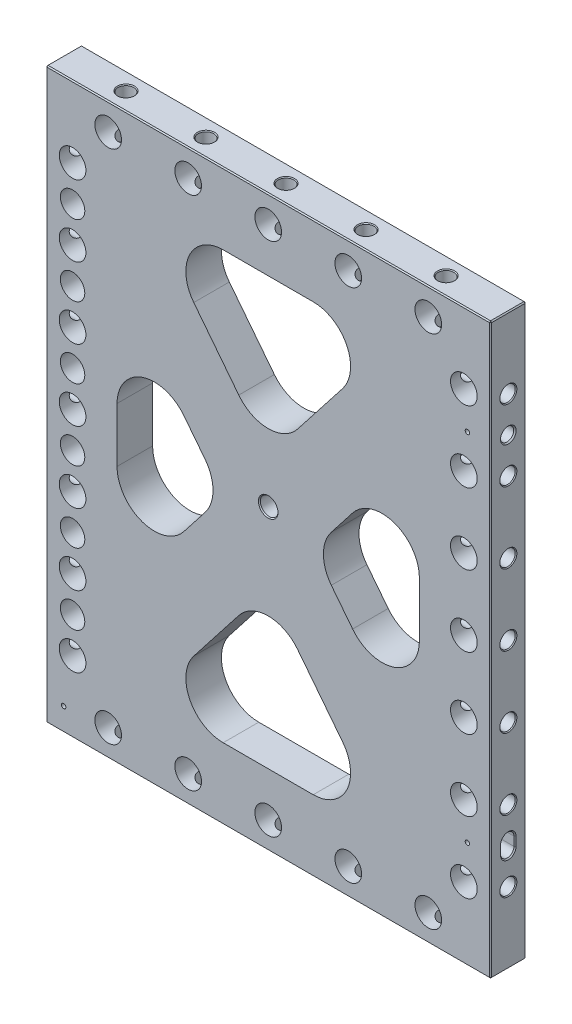
from build123d import *

# Parameters (mm, degrees)
SKETCH2_W                                     = 317.5
SKETCH2_H                                     = 406.4
EXTRUDE1_DEPTH                                = 12.7
TRIANGLES_CUT_EXTRUDE2_DEPTH                  = 26.4
TRIANGLES_FILLET1_R                           = 26.67
F_3_4_0_75_DIAMETER_HOLE2_D                   = 19.05
LPATTERN3_COUNT                               = 4
LPATTERN3_PITCH                               = 50.8
LPATTERN3_COL_COUNT                           = 4
LPATTERN3_COL_PITCH                           = 50.8
MIRROR1_COPY_1_D                              = 19.05
MIRROR1_COPY_2_D                              = 19.05
MIRROR1_COPY_3_D                              = 19.05
MIRROR1_COPY_7_D                              = 19.05
MIRROR1_COPY_8_D                              = 19.05
MIRROR1_COPY_9_D                              = 19.05
F_3_4_0_75_DIAMETER_HOLE1_D                   = 19.05
LPATTERN4_COUNT                               = 3
LPATTERN4_PITCH                               = 57.15
LPATTERN4_COL_COUNT                           = 3
LPATTERN4_COL_PITCH                           = 57.15
MIRROR2_COPY_1_D                              = 19.05
MIRROR2_COPY_2_D                              = 19.05
MIRROR2_COPY_5_D                              = 19.05
MIRROR2_COPY_6_D                              = 19.05
CBORE_FOR_3_8_SOCKET_HEAD_CAP_SCREW1_AT_COUNT = 2
CBORE_FOR_3_8_SOCKET_HEAD_CAP_SCREW1_AT_PITCH = 50.8
CBORE_FOR_3_8_SOCKET_HEAD_CAP_SCREW1_2_COUNT  = 2
CBORE_FOR_3_8_SOCKET_HEAD_CAP_SCREW1_2_PITCH  = 101.6
CBORE_FOR_3_8_SOCKET_HEAD_CAP_SCREW1_3_COUNT  = 2
CBORE_FOR_3_8_SOCKET_HEAD_CAP_SCREW1_3_PITCH  = 152.4
CBORE_FOR_3_8_SOCKET_HEAD_CAP_SCREW1_4_COUNT  = 2
CBORE_FOR_3_8_SOCKET_HEAD_CAP_SCREW1_4_PITCH  = 203.2
CBORE_FOR_3_8_SOCKET_HEAD_CAP_SCREW1_5_COUNT  = 2
CBORE_FOR_3_8_SOCKET_HEAD_CAP_SCREW1_5_PITCH  = 254
F_3_8_0_376_PIN_LOCATE1_D                     = 9.5504
F_3_8_0_376_PIN_LOCATE1_DEPTH                 = 19.05
F_3_8_0_376_PIN_LOCATE1_CSINK_D               = 11.176
F_3_8_0_376_PIN_LOCATE1_CSINK_ANGLE           = 82
F_3_8_0_376_PIN_LOCATE1_TIP                   = 2.869229628
SLOT_LOCATE1_DEPTH                            = 19.05
CHAMFER1_SIZE                                 = 0.762
F_1_8_0_125_DIAMETER_HOLE1_D                  = 3.175
F_1_8_0_125_DIAMETER_HOLE1_DEPTH              = 9.525
F_1_8_0_125_DIAMETER_HOLE1_TIP                = 0.953866233
CHAMFER2_SIZE                                 = 0.762


with BuildPart() as part:
    # Sketch2 → Extrude1 (new body, symmetric)
    with BuildSketch(Plane.XY):
        Rectangle(SKETCH2_W, SKETCH2_H)
    extrude(amount=EXTRUDE1_DEPTH, both=True)

    # Sketch8 → Triangles -- Cut-Extrude2 (cut, through all)
    with BuildSketch(Plane.XY.offset(12.7)):
        Polygon((-107.95, 96.918392895), (-32.23250555, 0), (-107.95, -96.918392895), align=None)
        Polygon((-86.82999445, 152.4), (0, 41.257607105), (86.82999445, 152.4), align=None)
        Polygon((107.95, 96.918392895), (107.95, -96.918392895), (32.23250555, 0), align=None)
        Polygon((0, -41.257607105), (-86.82999445, -152.4), (86.82999445, -152.4), align=None)
    extrude(amount=-TRIANGLES_CUT_EXTRUDE2_DEPTH, mode=Mode.SUBTRACT)

    # Triangles -- Fillet1
    triangles_fillet1_edges = [part.edges().sort_by_distance(p)[0] for p in [
        (-107.95, -96.918392895, 0),
        (-107.95, 96.918392895, 0),
        (-32.23250555, 0, 0),
        (-86.82999445, 152.4, 0),
        (86.82999445, 152.4, 0),
        (0, 41.257607105, 0),
        (32.23250555, 0, 0),
        (107.95, 96.918392895, 0),
        (107.95, -96.918392895, 0),
        (0, -41.257607105, 0),
        (86.82999445, -152.4, 0),
        (-86.82999445, -152.4, 0),
    ]]
    fillet(triangles_fillet1_edges, radius=TRIANGLES_FILLET1_R)

    # 3/4 (0.75) Diameter Hole2 (through all)
    with Locations(Plane.XY.offset(12.7)):
        with Locations((-139.7, 0)):
            f_3_4_0_75_diameter_hole2 = Hole(F_3_4_0_75_DIAMETER_HOLE2_D / 2)

    # Sketch5 → 7/16 (0.4375) Diameter Hole1 (revolve, cut)
    with BuildSketch(Plane(origin=(-158.75, 0, 0), x_dir=(0, 0, 1), z_dir=(0, 1, 0))):
        Polygon((0, 0), (0, 38.263531814), (5.55625, 34.925), (5.55625, 0.620911348), (6.096, 0), align=None)
    f_7_16_0_4375_diameter_hole1 = revolve(axis=Axis((-165.1, 0, 0), (1, 0, 0)), mode=Mode.SUBTRACT)

    # LPattern3: 3/4 (0.75) Diameter Hole2, 7/16 (0.4375) Diameter Hole1 ×4
    with Locations(*[(0, i * LPATTERN3_PITCH, 0) for i in range(1, LPATTERN3_COUNT)]):
        add(f_3_4_0_75_diameter_hole2, mode=Mode.SUBTRACT)
        add(f_7_16_0_4375_diameter_hole1, mode=Mode.SUBTRACT)

    # LPattern3 col: 3/4 (0.75) Diameter Hole2, 7/16 (0.4375) Diameter Hole1 ×4
    with Locations(*[(0, -i * LPATTERN3_COL_PITCH, 0) for i in range(1, LPATTERN3_COL_COUNT)]):
        add(f_3_4_0_75_diameter_hole2, mode=Mode.SUBTRACT)
        add(f_7_16_0_4375_diameter_hole1, mode=Mode.SUBTRACT)

    # Mirror1: 3/4 (0.75) Diameter Hole2, 7/16 (0.4375) Diameter Hole1 across plane
    add(f_3_4_0_75_diameter_hole2.mirror(Plane(origin=(0, 0, 0), x_dir=(0, 0, 1), z_dir=(1, 0, 0))), mode=Mode.SUBTRACT)
    add(f_7_16_0_4375_diameter_hole1.mirror(Plane(origin=(0, 0, 0), x_dir=(0, 0, 1), z_dir=(1, 0, 0))), mode=Mode.SUBTRACT)

    # Mirror1 copy 1 (through all)
    with Locations(Plane(origin=(0, 50.8, 12.7), x_dir=(-1, 0, 0), z_dir=(0, 0, 1))):
        with Locations((-139.7, 0)):
            Hole(MIRROR1_COPY_1_D / 2)

    # Mirror1 copy 2 (through all)
    with Locations(Plane(origin=(0, 101.6, 12.7), x_dir=(-1, 0, 0), z_dir=(0, 0, 1))):
        with Locations((-139.7, 0)):
            Hole(MIRROR1_COPY_2_D / 2)

    # Mirror1 copy 3 (through all)
    with Locations(Plane(origin=(0, 152.4, 12.7), x_dir=(-1, 0, 0), z_dir=(0, 0, 1))):
        with Locations((-139.7, 0)):
            Hole(MIRROR1_COPY_3_D / 2)

    # Mirror1 copy 4 sketch → Mirror1 copy 4 (revolve, cut)
    with BuildSketch(Plane(origin=(158.75, 50.8, 0), x_dir=(0, 0, 1), z_dir=(0, 1, 0))):
        Polygon((0, 0), (0, -38.263531814), (5.55625, -34.925), (5.55625, -0.620911348), (6.096, 0), align=None)
    revolve(axis=Axis((165.1, 50.8, 0), (1, 0, 0)), mode=Mode.SUBTRACT)

    # Mirror1 copy 5 sketch → Mirror1 copy 5 (revolve, cut)
    with BuildSketch(Plane(origin=(158.75, 101.6, 0), x_dir=(0, 0, 1), z_dir=(0, 1, 0))):
        Polygon((0, 0), (0, -38.263531814), (5.55625, -34.925), (5.55625, -0.620911348), (6.096, 0), align=None)
    revolve(axis=Axis((165.1, 101.6, 0), (1, 0, 0)), mode=Mode.SUBTRACT)

    # Mirror1 copy 6 sketch → Mirror1 copy 6 (revolve, cut)
    with BuildSketch(Plane(origin=(158.75, 152.4, 0), x_dir=(0, 0, 1), z_dir=(0, 1, 0))):
        Polygon((0, 0), (0, -38.263531814), (5.55625, -34.925), (5.55625, -0.620911348), (6.096, 0), align=None)
    revolve(axis=Axis((165.1, 152.4, 0), (1, 0, 0)), mode=Mode.SUBTRACT)

    # Mirror1 copy 7 (through all)
    with Locations(Plane(origin=(0, -50.8, 12.7), x_dir=(-1, 0, 0), z_dir=(0, 0, 1))):
        with Locations((-139.7, 0)):
            Hole(MIRROR1_COPY_7_D / 2)

    # Mirror1 copy 8 (through all)
    with Locations(Plane(origin=(0, -101.6, 12.7), x_dir=(-1, 0, 0), z_dir=(0, 0, 1))):
        with Locations((-139.7, 0)):
            Hole(MIRROR1_COPY_8_D / 2)

    # Mirror1 copy 9 (through all)
    with Locations(Plane(origin=(0, -152.4, 12.7), x_dir=(-1, 0, 0), z_dir=(0, 0, 1))):
        with Locations((-139.7, 0)):
            Hole(MIRROR1_COPY_9_D / 2)

    # Mirror1 copy 10 sketch → Mirror1 copy 10 (revolve, cut)
    with BuildSketch(Plane(origin=(158.75, -50.8, 0), x_dir=(0, 0, 1), z_dir=(0, 1, 0))):
        Polygon((0, 0), (0, -38.263531814), (5.55625, -34.925), (5.55625, -0.620911348), (6.096, 0), align=None)
    revolve(axis=Axis((165.1, -50.8, 0), (1, 0, 0)), mode=Mode.SUBTRACT)

    # Mirror1 copy 11 sketch → Mirror1 copy 11 (revolve, cut)
    with BuildSketch(Plane(origin=(158.75, -101.6, 0), x_dir=(0, 0, 1), z_dir=(0, 1, 0))):
        Polygon((0, 0), (0, -38.263531814), (5.55625, -34.925), (5.55625, -0.620911348), (6.096, 0), align=None)
    revolve(axis=Axis((165.1, -101.6, 0), (1, 0, 0)), mode=Mode.SUBTRACT)

    # Mirror1 copy 12 sketch → Mirror1 copy 12 (revolve, cut)
    with BuildSketch(Plane(origin=(158.75, -152.4, 0), x_dir=(0, 0, 1), z_dir=(0, 1, 0))):
        Polygon((0, 0), (0, -38.263531814), (5.55625, -34.925), (5.55625, -0.620911348), (6.096, 0), align=None)
    revolve(axis=Axis((165.1, -152.4, 0), (1, 0, 0)), mode=Mode.SUBTRACT)

    # 3/4 (0.75) Diameter Hole1 (through all)
    with Locations(Plane.XY.offset(12.7)):
        with Locations((0, -184.15)):
            f_3_4_0_75_diameter_hole1 = Hole(F_3_4_0_75_DIAMETER_HOLE1_D / 2)

    # Sketch12 → 7/16 (0.4375) Diameter Hole2 (revolve, cut)
    with BuildSketch(Plane(origin=(0, -203.2, 0), x_dir=(0, 0, -1), z_dir=(1, 0, 0))):
        Polygon((0, 0), (0, 38.263531814), (5.55625, 34.925), (5.55625, 0.620911348), (6.096, 0), align=None)
    f_7_16_0_4375_diameter_hole2 = revolve(axis=Axis((0, -209.55, 0), (0, 1, 0)), mode=Mode.SUBTRACT)

    # LPattern4: 3/4 (0.75) Diameter Hole1, 7/16 (0.4375) Diameter Hole2 ×3
    with Locations(*[(i * LPATTERN4_PITCH, 0, 0) for i in range(1, LPATTERN4_COUNT)]):
        add(f_3_4_0_75_diameter_hole1, mode=Mode.SUBTRACT)
        add(f_7_16_0_4375_diameter_hole2, mode=Mode.SUBTRACT)

    # LPattern4 col: 3/4 (0.75) Diameter Hole1, 7/16 (0.4375) Diameter Hole2 ×3
    with Locations(*[(-i * LPATTERN4_COL_PITCH, 0, 0) for i in range(1, LPATTERN4_COL_COUNT)]):
        add(f_3_4_0_75_diameter_hole1, mode=Mode.SUBTRACT)
        add(f_7_16_0_4375_diameter_hole2, mode=Mode.SUBTRACT)

    # Mirror2: 3/4 (0.75) Diameter Hole1, 7/16 (0.4375) Diameter Hole2 across plane
    add(f_3_4_0_75_diameter_hole1.mirror(Plane.ZX), mode=Mode.SUBTRACT)
    add(f_7_16_0_4375_diameter_hole2.mirror(Plane.ZX), mode=Mode.SUBTRACT)

    # Mirror2 copy 1 (through all)
    with Locations(Plane(origin=(57.15, 0, 12.7), x_dir=(1, 0, 0), z_dir=(0, 0, 1))):
        with Locations((0, 184.15)):
            Hole(MIRROR2_COPY_1_D / 2)

    # Mirror2 copy 2 (through all)
    with Locations(Plane(origin=(114.3, 0, 12.7), x_dir=(1, 0, 0), z_dir=(0, 0, 1))):
        with Locations((0, 184.15)):
            Hole(MIRROR2_COPY_2_D / 2)

    # Mirror2 copy 3 sketch → Mirror2 copy 3 (revolve, cut)
    with BuildSketch(Plane(origin=(57.15, 203.2, 0), x_dir=(0, 0, -1), z_dir=(1, 0, 0))):
        Polygon((0, 0), (0, -38.263531814), (5.55625, -34.925), (5.55625, -0.620911348), (6.096, 0), align=None)
    revolve(axis=Axis((57.15, 209.55, 0), (0, 1, 0)), mode=Mode.SUBTRACT)

    # Mirror2 copy 4 sketch → Mirror2 copy 4 (revolve, cut)
    with BuildSketch(Plane(origin=(114.3, 203.2, 0), x_dir=(0, 0, -1), z_dir=(1, 0, 0))):
        Polygon((0, 0), (0, -38.263531814), (5.55625, -34.925), (5.55625, -0.620911348), (6.096, 0), align=None)
    revolve(axis=Axis((114.3, 209.55, 0), (0, 1, 0)), mode=Mode.SUBTRACT)

    # Mirror2 copy 5 (through all)
    with Locations(Plane(origin=(-57.15, 0, 12.7), x_dir=(1, 0, 0), z_dir=(0, 0, 1))):
        with Locations((0, 184.15)):
            Hole(MIRROR2_COPY_5_D / 2)

    # Mirror2 copy 6 (through all)
    with Locations(Plane(origin=(-114.3, 0, 12.7), x_dir=(1, 0, 0), z_dir=(0, 0, 1))):
        with Locations((0, 184.15)):
            Hole(MIRROR2_COPY_6_D / 2)

    # Mirror2 copy 7 sketch → Mirror2 copy 7 (revolve, cut)
    with BuildSketch(Plane(origin=(-57.15, 203.2, 0), x_dir=(0, 0, -1), z_dir=(1, 0, 0))):
        Polygon((0, 0), (0, -38.263531814), (5.55625, -34.925), (5.55625, -0.620911348), (6.096, 0), align=None)
    revolve(axis=Axis((-57.15, 209.55, 0), (0, 1, 0)), mode=Mode.SUBTRACT)

    # Mirror2 copy 8 sketch → Mirror2 copy 8 (revolve, cut)
    with BuildSketch(Plane(origin=(-114.3, 203.2, 0), x_dir=(0, 0, -1), z_dir=(1, 0, 0))):
        Polygon((0, 0), (0, -38.263531814), (5.55625, -34.925), (5.55625, -0.620911348), (6.096, 0), align=None)
    revolve(axis=Axis((-114.3, 209.55, 0), (0, 1, 0)), mode=Mode.SUBTRACT)

    # Sketch17 → CBORE for 3/8 Socket Head Cap Screw1 (revolve, cut)
    with BuildSketch(Plane(origin=(-139.7, 127, 12.7), x_dir=(0, -1, 0), z_dir=(1, 0, 0))):
        Polygon((0, 0), (0, 25.4), (5.842, 25.4), (5.15874, 24.613999282), (5.15874, 12.7), (8.73125, 12.7), (8.73125, 0), align=None)
    cbore_for_3_8_socket_head_cap_screw1 = revolve(axis=Axis((-139.7, 127, 19.05), (0, 0, -1)), mode=Mode.SUBTRACT)

    # CBORE for 3/8 Socket Head Cap Screw1 at: CBORE for 3/8 Socket Head Cap Screw1 ×2
    with Locations(*[(0, -i * CBORE_FOR_3_8_SOCKET_HEAD_CAP_SCREW1_AT_PITCH, 0) for i in range(1, CBORE_FOR_3_8_SOCKET_HEAD_CAP_SCREW1_AT_COUNT)]):
        add(cbore_for_3_8_socket_head_cap_screw1, mode=Mode.SUBTRACT)

    # CBORE for 3_8 Socket Head Cap Screw1 2: CBORE for 3/8 Socket Head Cap Screw1 ×2
    with Locations(*[(0, -i * CBORE_FOR_3_8_SOCKET_HEAD_CAP_SCREW1_2_PITCH, 0) for i in range(1, CBORE_FOR_3_8_SOCKET_HEAD_CAP_SCREW1_2_COUNT)]):
        add(cbore_for_3_8_socket_head_cap_screw1, mode=Mode.SUBTRACT)

    # CBORE for 3_8 Socket Head Cap Screw1 3: CBORE for 3/8 Socket Head Cap Screw1 ×2
    with Locations(*[(0, -i * CBORE_FOR_3_8_SOCKET_HEAD_CAP_SCREW1_3_PITCH, 0) for i in range(1, CBORE_FOR_3_8_SOCKET_HEAD_CAP_SCREW1_3_COUNT)]):
        add(cbore_for_3_8_socket_head_cap_screw1, mode=Mode.SUBTRACT)

    # CBORE for 3_8 Socket Head Cap Screw1 4: CBORE for 3/8 Socket Head Cap Screw1 ×2
    with Locations(*[(0, -i * CBORE_FOR_3_8_SOCKET_HEAD_CAP_SCREW1_4_PITCH, 0) for i in range(1, CBORE_FOR_3_8_SOCKET_HEAD_CAP_SCREW1_4_COUNT)]):
        add(cbore_for_3_8_socket_head_cap_screw1, mode=Mode.SUBTRACT)

    # CBORE for 3_8 Socket Head Cap Screw1 5: CBORE for 3/8 Socket Head Cap Screw1 ×2
    with Locations(*[(0, -i * CBORE_FOR_3_8_SOCKET_HEAD_CAP_SCREW1_5_PITCH, 0) for i in range(1, CBORE_FOR_3_8_SOCKET_HEAD_CAP_SCREW1_5_COUNT)]):
        add(cbore_for_3_8_socket_head_cap_screw1, mode=Mode.SUBTRACT)

    # Sketch20 → 3/8 (0.375) Pin + Lead-In Hole1 (revolve, cut)
    with BuildSketch(Plane(origin=(-146.05, -203.2, 0), x_dir=(0, 0, -1), z_dir=(1, 0, 0))):
        Polygon((0, 0), (0, 21.911598698), (4.7625, 19.05), (4.7625, 3.175), (4.7879, 3.175), (4.7879, 0.628216187), (5.334, 0), align=None)
    revolve(axis=Axis((-146.05, -209.55, 0), (0, 1, 0)), mode=Mode.SUBTRACT)

    # 3/8 (0.376) Pin Locate1
    with Locations(Plane(origin=(158.75, 0, 0), x_dir=(0, 0, -1), z_dir=(1, 0, 0))):
        with Locations((0, 127)):
            CounterSinkHole(F_3_8_0_376_PIN_LOCATE1_D / 2, F_3_8_0_376_PIN_LOCATE1_CSINK_D / 2, depth=F_3_8_0_376_PIN_LOCATE1_DEPTH, counter_sink_angle=F_3_8_0_376_PIN_LOCATE1_CSINK_ANGLE)
            with Locations((0, 0, -(F_3_8_0_376_PIN_LOCATE1_DEPTH + F_3_8_0_376_PIN_LOCATE1_TIP / 2))):  # 118° drill point
                Cone(0, F_3_8_0_376_PIN_LOCATE1_D / 2, F_3_8_0_376_PIN_LOCATE1_TIP, mode=Mode.SUBTRACT)

    # Sketch24 → Slot Locate1 (cut)
    with BuildSketch(Plane(origin=(158.75, 0, 0), x_dir=(0, 0, -1), z_dir=(1, 0, 0))):
        with BuildLine():
            Line((-4.7752, -123.825), (-4.7752, -130.175))
            ThreePointArc((-4.7752, -130.175), (0, -134.9502), (4.7752, -130.175))
            Line((4.7752, -130.175), (4.7752, -123.825))
            ThreePointArc((4.7752, -123.825), (0, -119.0498), (-4.7752, -123.825))
        make_face()
    extrude(amount=-SLOT_LOCATE1_DEPTH, mode=Mode.SUBTRACT)

    # Chamfer1
    chamfer1_edges = [part.edges().sort_by_distance(p)[0] for p in [
        (158.75, -119.0498, 0),
        (158.75, -127, 4.7752),
        (158.75, -134.9502, 0),
        (158.75, -127, -4.7752),
    ]]
    chamfer(chamfer1_edges, length=CHAMFER1_SIZE)

    # 1/8 (0.125) Diameter Hole1
    with Locations(Plane.XY.offset(12.7)):
        with Locations((-146.05, -186.69), (142.24, 127), (142.24, -127)):
            Hole(F_1_8_0_125_DIAMETER_HOLE1_D / 2, depth=F_1_8_0_125_DIAMETER_HOLE1_DEPTH)
            with Locations((0, 0, -(F_1_8_0_125_DIAMETER_HOLE1_DEPTH + F_1_8_0_125_DIAMETER_HOLE1_TIP / 2))):  # 118° drill point
                Cone(0, F_1_8_0_125_DIAMETER_HOLE1_D / 2, F_1_8_0_125_DIAMETER_HOLE1_TIP, mode=Mode.SUBTRACT)

    # Sketch27 → 1/2 (0.5) Diameter Hole1 (revolve, cut)
    with BuildSketch(Plane(origin=(0, 9.525, -12.7), x_dir=(0, 1, 0), z_dir=(1, 0, 0))):
        Polygon((0, 0), (0, 25.4), (6.985, 25.4), (6.35, 24.669516061), (6.35, 0.730483939), (6.985, 0), align=None)
    revolve(axis=Axis((0, 9.525, -19.05), (0, 0, 1)), mode=Mode.SUBTRACT)

    # Chamfer2
    chamfer2_edges = [part.edges().sort_by_distance(p)[0] for p in [
        (158.75, 0, 12.7),
        (0, 203.2, 12.7),
        (-158.75, 0, 12.7),
        (0, 203.2, -12.7),
        (158.75, 0, -12.7),
        (0, -203.2, -12.7),
        (-158.75, 0, -12.7),
        (0, -203.2, 12.7),
        (-158.75, 203.2, 0),
        (158.75, 203.2, 0),
        (158.75, -203.2, 0),
        (-158.75, -203.2, 0),
    ]]
    chamfer(chamfer2_edges, length=CHAMFER2_SIZE)


solid = part.part
